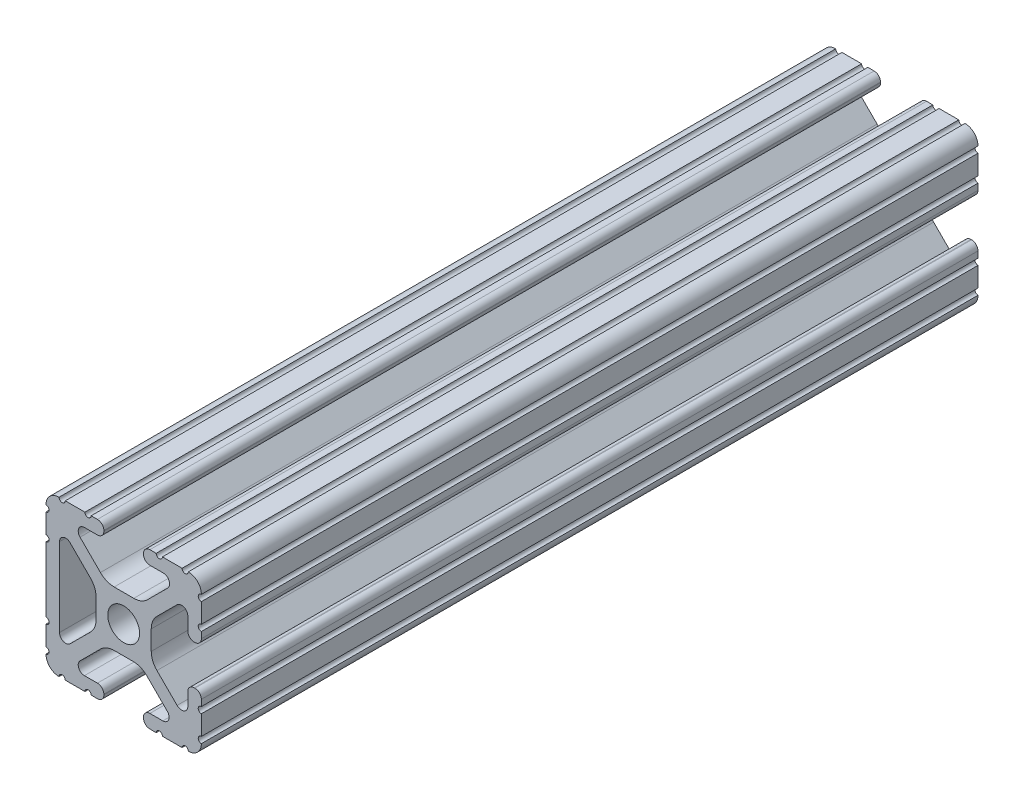
from build123d import *

# Parameters (mm, degrees)
SKETCH1_R           = 2.6035
BOSS_EXTRUDE1_DEPTH = 127


with BuildPart() as part:
    # Sketch1 → Boss-Extrude1 (new body)
    with BuildSketch(Plane(origin=(0, 0, -152.4), x_dir=(-1, 0, 0), z_dir=(0, 0, -1))):
        with BuildLine():
            Line((6.416409763, -10.4902), (4.28752, -10.4902))
            ThreePointArc((4.28752, -10.4902), (3.545750844, -10.797450844), (3.2385, -11.53922))
            Line((3.2385, -11.53922), (3.2385, -11.65098))
            ThreePointArc((3.2385, -11.65098), (3.545750844, -12.392749156), (4.28752, -12.7))
            Line((4.28752, -12.7), (5.3170836, -12.7))
            ThreePointArc((5.3170836, -12.7), (5.8250836, -12.192), (6.3330836, -12.7))
            Line((6.3330836, -12.7), (9.5504, -12.7))
            ThreePointArc((9.5504, -12.7), (10.058323491, -12.192000006), (10.566399977, -12.699846982))
            ThreePointArc((10.566399977, -12.699846982), (12.082522516, -12.082522516), (12.699846982, -10.566399977))
            ThreePointArc((12.699846982, -10.566399977), (12.192000006, -10.058323491), (12.7, -9.5504))
            Line((12.7, -9.5504), (12.7, -6.3330836))
            ThreePointArc((12.7, -6.3330836), (12.192, -5.8250836), (12.7, -5.3170836))
            Line((12.7, -5.3170836), (12.7, 5.3171344))
            ThreePointArc((12.7, 5.3171344), (12.192, 5.8251344), (12.7, 6.3331344))
            Line((12.7, 6.3331344), (12.7, 9.5504))
            ThreePointArc((12.7, 9.5504), (12.192000006, 10.058323491), (12.699846982, 10.566399977))
            ThreePointArc((12.699846982, 10.566399977), (12.082522516, 12.082522516), (10.566399977, 12.699846982))
            ThreePointArc((10.566399977, 12.699846982), (10.058323491, 12.192000006), (9.5504, 12.7))
            Line((9.5504, 12.7), (6.3331344, 12.7))
            ThreePointArc((6.3331344, 12.7), (5.8251344, 12.192), (5.3171344, 12.7))
            Line((5.3171344, 12.7), (4.2874692, 12.7))
            ThreePointArc((4.2874692, 12.7), (3.545700044, 12.392749156), (3.2384492, 11.65098))
            Line((3.2384492, 11.65098), (3.2384492, 11.53922))
            ThreePointArc((3.2384492, 11.53922), (3.545700044, 10.797450844), (4.2874692, 10.4902))
            Line((4.2874692, 10.4902), (6.416384363, 10.4902))
            ThreePointArc((6.416384363, 10.4902), (7.355223148, 9.862578342), (7.134149423, 8.755124678))
            Line((7.134149423, 8.755124678), (3.796632915, 5.423689619))
            ThreePointArc((3.796632915, 5.423689619), (2.767299421, 4.736928798), (1.553617102, 4.4958))
            Line((1.553617102, 4.4958), (-1.657299581, 4.4958))
            ThreePointArc((-1.657299581, 4.4958), (-2.8709819, 4.736928798), (-3.900315394, 5.423689619))
            Line((-3.900315394, 5.423689619), (-7.207191475, 8.724540082))
            ThreePointArc((-7.207191475, 8.724540082), (-7.43216212, 9.851515102), (-6.476774195, 10.4902))
            Line((-6.476774195, 10.4902), (-4.2874692, 10.4902))
            ThreePointArc((-4.2874692, 10.4902), (-3.545700044, 10.797450844), (-3.2384492, 11.53922))
            Line((-3.2384492, 11.53922), (-3.2384492, 11.65098))
            ThreePointArc((-3.2384492, 11.65098), (-3.545700044, 12.392749156), (-4.2874692, 12.7))
            Line((-4.2874692, 12.7), (-5.3170836, 12.7))
            ThreePointArc((-5.3170836, 12.7), (-5.8250836, 12.192), (-6.3330836, 12.7))
            Line((-6.3330836, 12.7), (-9.5504, 12.7))
            ThreePointArc((-9.5504, 12.7), (-10.058323491, 12.192000006), (-10.566399977, 12.699846982))
            ThreePointArc((-10.566399977, 12.699846982), (-12.082522516, 12.082522516), (-12.699846982, 10.566399977))
            ThreePointArc((-12.699846982, 10.566399977), (-12.192000006, 10.058323491), (-12.7, 9.5504))
            Line((-12.7, 9.5504), (-12.7, 6.3331344))
            ThreePointArc((-12.7, 6.3331344), (-12.192, 5.8251344), (-12.7, 5.3171344))
            Line((-12.7, 5.3171344), (-12.7, 4.287470133))
            ThreePointArc((-12.7, 4.287470133), (-12.392749156, 3.545700977), (-11.65098, 3.238450133))
            Line((-11.65098, 3.238450133), (-11.53922, 3.238450133))
            ThreePointArc((-11.53922, 3.238450133), (-10.797450844, 3.545700977), (-10.4902, 4.287470133))
            Line((-10.4902, 4.287470133), (-10.4902, 6.402089023))
            ThreePointArc((-10.4902, 6.402089023), (-9.856394933, 7.351113629), (-8.736962546, 7.129240479))
            Line((-8.736962546, 7.129240479), (-5.440484187, 3.838768792))
            ThreePointArc((-5.440484187, 3.838768792), (-4.75073678, 2.808015636), (-4.5085, 1.591658411))
            Line((-4.5085, 1.591658411), (-4.5085, -1.591658411))
            ThreePointArc((-4.5085, -1.591658411), (-4.75073678, -2.808015636), (-5.440484187, -3.838768792))
            Line((-5.440484187, -3.838768792), (-8.736962546, -7.129240479))
            ThreePointArc((-8.736962546, -7.129240479), (-9.856394933, -7.351113629), (-10.4902, -6.402089023))
            Line((-10.4902, -6.402089023), (-10.4902, -4.287470133))
            ThreePointArc((-10.4902, -4.287470133), (-10.797450844, -3.545700977), (-11.53922, -3.238450133))
            Line((-11.53922, -3.238450133), (-11.65098, -3.238450133))
            ThreePointArc((-11.65098, -3.238450133), (-12.392749156, -3.545700977), (-12.7, -4.287470133))
            Line((-12.7, -4.287470133), (-12.7, -5.3170836))
            ThreePointArc((-12.7, -5.3170836), (-12.192, -5.8250836), (-12.7, -6.3330836))
            Line((-12.7, -6.3330836), (-12.7, -9.5504))
            ThreePointArc((-12.7, -9.5504), (-12.192000006, -10.058323491), (-12.699846982, -10.566399977))
            ThreePointArc((-12.699846982, -10.566399977), (-12.082522516, -12.082522516), (-10.566399977, -12.699846982))
            ThreePointArc((-10.566399977, -12.699846982), (-10.058323491, -12.192000006), (-9.5504, -12.7))
            Line((-9.5504, -12.7), (-6.3331344, -12.7))
            ThreePointArc((-6.3331344, -12.7), (-5.8251344, -12.192), (-5.3171344, -12.7))
            Line((-5.3171344, -12.7), (-4.28752, -12.7))
            ThreePointArc((-4.28752, -12.7), (-3.545750844, -12.392749156), (-3.2385, -11.65098))
            Line((-3.2385, -11.65098), (-3.2385, -11.53922))
            ThreePointArc((-3.2385, -11.53922), (-3.545750844, -10.797450844), (-4.28752, -10.4902))
            Line((-4.28752, -10.4902), (-6.40834956, -10.4902))
            ThreePointArc((-6.40834956, -10.4902), (-7.350269456, -9.860518594), (-7.128470204, -8.749430454))
            Line((-7.128470204, -8.749430454), (-3.796658315, -5.423689619))
            ThreePointArc((-3.796658315, -5.423689619), (-2.767324821, -4.736928798), (-1.553642502, -4.4958))
            Line((-1.553642502, -4.4958), (1.553642502, -4.4958))
            ThreePointArc((1.553642502, -4.4958), (2.767324821, -4.736928798), (3.796658315, -5.423689619))
            Line((3.796658315, -5.423689619), (7.134174823, -8.755124678))
            ThreePointArc((7.134174823, -8.755124678), (7.355248548, -9.862578342), (6.416409763, -10.4902))
        make_face()
        Circle(SKETCH1_R, mode=Mode.SUBTRACT)
        with BuildLine():
            Line((10.4902, 6.446436794), (10.4902, -6.425372487))
            ThreePointArc((10.4902, -6.425372487), (9.862352148, -7.36547709), (8.753441447, -7.145689354))
            Line((8.753441447, -7.145689354), (5.440484187, -3.838768792))
            ThreePointArc((5.440484187, -3.838768792), (4.75073678, -2.808015636), (4.5085, -1.591658411))
            Line((4.5085, -1.591658411), (4.5085, 1.591658411))
            ThreePointArc((4.5085, 1.591658411), (4.75073678, 2.808015636), (5.440484187, 3.838768792))
            Line((5.440484187, 3.838768792), (8.768349738, 7.160570479))
            ThreePointArc((8.768349738, 7.160570479), (9.867741577, 7.378471563), (10.4902, 6.446436794))
        make_face(mode=Mode.SUBTRACT)
    extrude(amount=-BOSS_EXTRUDE1_DEPTH)


solid = part.part
